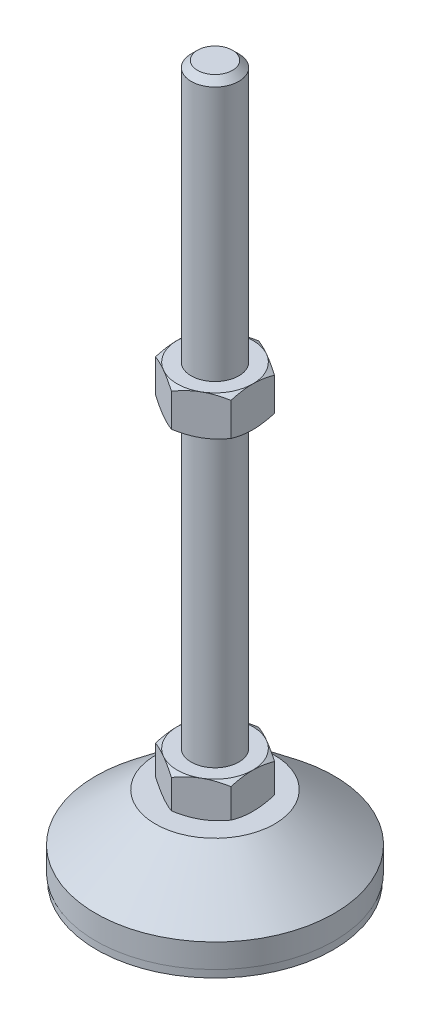
from build123d import *

# Parameters (mm, degrees)
EXTRUDE_1_DEPTH = 9
EXTRUDE_2_DEPTH = 10


with BuildPart() as part:
    # Эскиз1 → Повернуть1 (revolve)
    with BuildSketch(Plane.XY, mode=Mode.PRIVATE) as revolve_1_sk:
        Polygon((0, 0), (-29.8, 0), (-29.8, 2), (-30, 2), (-30, 8), (-15, 20), (-6, 20), (-6, 29), (-6, 177.4), (-4.4, 179), (0, 179), align=None)
    revolve(revolve_1_sk.sketch.rotate(Axis((0, 0, 0), (0, 1, 0)), 180), axis=Axis((0, 0, 0), (0, 1, 0)))  # turned: the seam where the file's is

    # Эскиз2 → Бобышка-Вытянуть1 (add)
    with BuildSketch(Plane(origin=(0, 20, 0), x_dir=(1, 0, 0), z_dir=(0, 1, 0))):
        Polygon((0, 10.969655115), (-9.5, 5.484827557), (-9.5, -5.484827557), (0, -10.969655115), (9.5, -5.484827557), (9.5, 5.484827557), align=None)
    extrude(amount=EXTRUDE_1_DEPTH)

    # Эскиз3 → Бобышка-Вытянуть2 (add)
    with BuildSketch(Plane(origin=(0, 103.2, 0), x_dir=(1, 0, 0), z_dir=(0, 1, 0))):
        Polygon((9.5, 5.484827557), (0, 10.969655115), (-9.5, 5.484827557), (-9.5, -5.484827557), (0, -10.969655115), (9.5, -5.484827557), align=None)
    extrude(amount=EXTRUDE_2_DEPTH)

    # Эскиз4 → Вырез-Повернуть2 (revolve, cut)
    with BuildSketch(Plane.XY, mode=Mode.PRIVATE) as cut_revolve_2_sk:
        Polygon((-18.160254038, 113.2), (-9.5, 113.2), (-18.160254038, 108.2), align=None)
        Polygon((-18.160254038, 103.2), (-18.160254038, 108.2), (-9.5, 103.2), align=None)
        Polygon((-17.294228634, 29), (-17.294228634, 24.5), (-9.5, 29), align=None)
        Polygon((-17.294228634, 24.5), (-17.294228634, 20), (-9.5, 20), align=None)
    revolve(cut_revolve_2_sk.sketch.rotate(Axis((0, 179, 0), (0, -1, 0)), 180), axis=Axis((0, 179, 0), (0, -1, 0)), mode=Mode.SUBTRACT)  # turned: the seam where the file's is


solid = part.part
